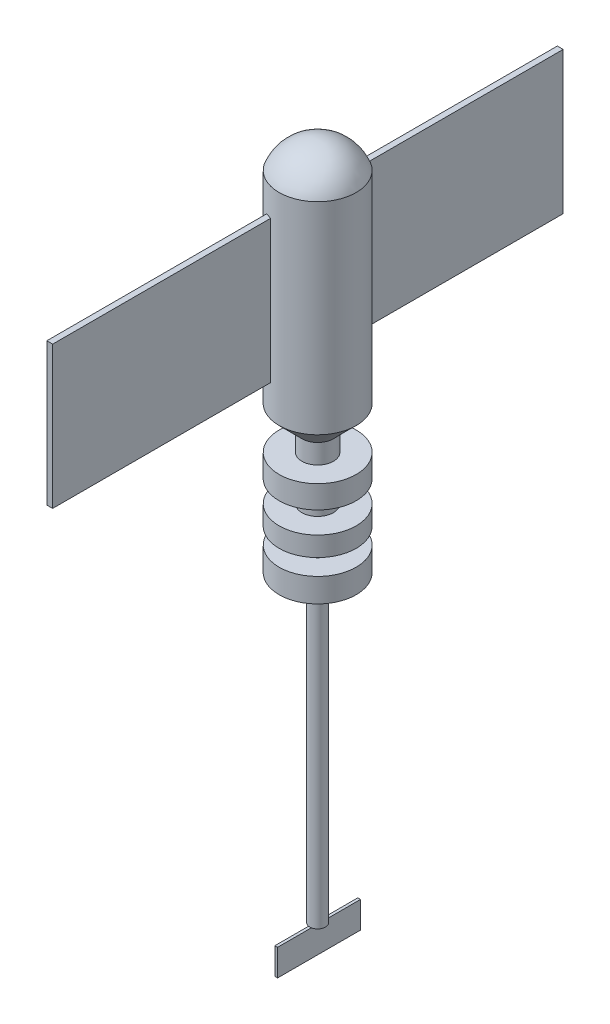
from build123d import *

# Parameters (mm, degrees)
DOME1_FACE_RADIUS   = 14.488501688
DOME1_HEIGHT        = 10
SKETCH4_W           = 2.198846944
SKETCH4_H           = 53.513980491
BOSS_EXTRUDE1_DEPTH = 96
SKETCH5_R           = 2.935842155
BOSS_EXTRUDE2_DEPTH = 114
SKETCH7_W           = 1.028080296
SKETCH7_H           = 31.194109998
BOSS_EXTRUDE3_DEPTH = 10


with BuildPart() as part:
    # Sketch1 → Revolve1 (revolve)
    with BuildSketch(Plane.XY):
        Polygon((0, 78.360347155), (-14.488501688, 78.360347155), (-14.488501688, 2.448760849), (-5.917838717, -6.121902122), (-5.917838717, -13.468184667), (-14.488501688, -13.468184667), (-14.488501688, -22.038847637), (-5.917838717, -22.038847637), (-5.917838717, -30.201383799), (-14.488501688, -30.201383799), (-14.488501688, -37.547666345), (-5.917838717, -37.547666345), (-5.917838717, -43.669568467), (-14.488501688, -43.669568467), (-14.488501688, -52.648358245), (-5.917838717, -52.648358245), (0, -52.648358245), align=None)
    revolve(axis=Axis((0, 93.052912247, 0), (0, -1, 0)))

    # Dome1: a dome of height H over a round flat face of radius A is a cap of a sphere of radius (A * A + H * H) / (2 * H)
    dome1_r = (DOME1_FACE_RADIUS * DOME1_FACE_RADIUS + DOME1_HEIGHT * DOME1_HEIGHT) / (2 * DOME1_HEIGHT)
    dome1_base = Plane((0, 78.360347155, 0), z_dir=(0, 1, 0))
    with Locations(dome1_base.offset(DOME1_HEIGHT - dome1_r)):
        dome1_ball = Sphere(dome1_r, mode=Mode.PRIVATE)
    add(split(dome1_ball, bisect_by=dome1_base, keep=Keep.TOP, mode=Mode.PRIVATE))

    # Sketch4 → Boss-Extrude1 (add)
    with BuildSketch(Plane.XY):
        with Locations((-4.762390363, 41.15200271)):
            Rectangle(SKETCH4_W, SKETCH4_H)
    boss_extrude1 = extrude(amount=BOSS_EXTRUDE1_DEPTH)

    # Mirror1: Boss-Extrude1 across plane
    add(boss_extrude1.mirror(Plane.XY))

    # Sketch5 → Boss-Extrude2 (add)
    with BuildSketch(Plane.XZ.offset(52.648358245)):
        Circle(SKETCH5_R)
    extrude(amount=BOSS_EXTRUDE2_DEPTH)

    # Sketch7 → Boss-Extrude3 (add)
    with BuildSketch(Plane.XZ.offset(166.648358245)):
        Rectangle(SKETCH7_W, SKETCH7_H)
    extrude(amount=BOSS_EXTRUDE3_DEPTH)


solid = part.part
